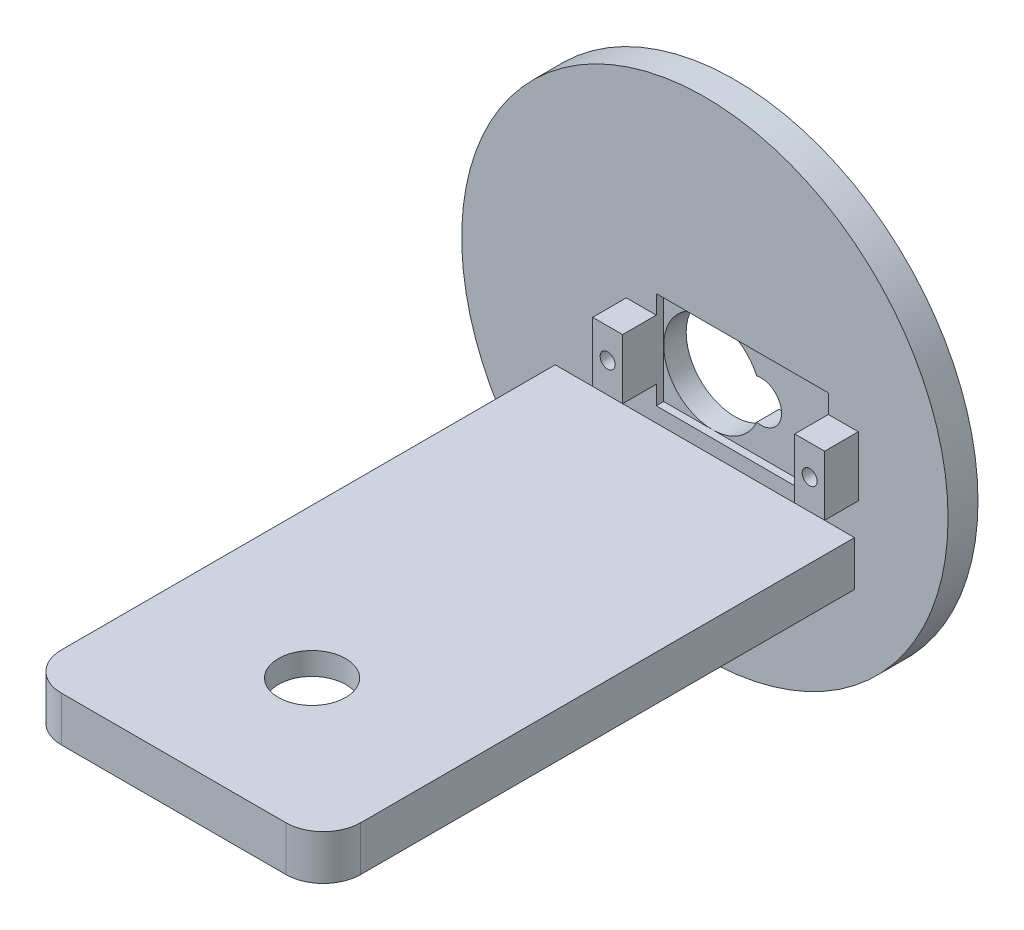
from build123d import *

# Parameters (mm, degrees)
ESBO_O1_R                = 32.5
RESSALTO_EXTRUS_O1_DEPTH = 4
ESBO_O2_W                = 4
ESBO_O2_H                = 8
ESBO_O2_R                = 1
RESSALTO_EXTRUS_O3_DEPTH = 4.5
ESBO_O3_W                = 23
ESBO_O3_H                = 13
CORTE_EXTRUS_O1_DEPTH    = 1
ESBO_O4_W                = 40
ESBO_O4_H                = 6
RESSALTO_EXTRUS_O4_DEPTH = 71
ESBO_O5_R                = 4.5
CORTE_EXTRUS_O2_DEPTH    = 61
CORTE_EXTRUS_O3_DEPTH    = 3
FILETE1_R                = 5


with BuildPart() as part:
    # Esboço1 → Ressalto-extrusão1 (new body)
    with BuildSketch(Plane.XY):
        Circle(ESBO_O1_R)
        with BuildLine():
            ThreePointArc((5.921389022, 2.680886429), (-6.5, 0), (5.921389022, -2.680886429))
            ThreePointArc((5.921389022, -2.680886429), (9.242616034, 0), (5.921389022, 2.680886429))
        make_face(mode=Mode.SUBTRACT)
    extrude(amount=RESSALTO_EXTRUS_O1_DEPTH)

    # Esboço2 → Ressalto-extrusão3 (add)
    with BuildSketch(Plane.XY.offset(4)):
        with Locations((-8.5, 0)):
            Rectangle(ESBO_O2_W, ESBO_O2_H)
        with Locations((-8.5, 0)):
            Circle(ESBO_O2_R, mode=Mode.SUBTRACT)
        with Locations((18.5, 0)):
            Rectangle(ESBO_O2_W, ESBO_O2_H)
        with Locations((18.5, 0)):
            Circle(ESBO_O2_R, mode=Mode.SUBTRACT)
    extrude(amount=RESSALTO_EXTRUS_O3_DEPTH)

    # Esboço3 → Corte-extrusão1 (cut)
    with BuildSketch(Plane.XY.offset(4)):
        with Locations((5, 0)):
            Rectangle(ESBO_O3_W, ESBO_O3_H)
    extrude(amount=-CORTE_EXTRUS_O1_DEPTH, mode=Mode.SUBTRACT)

    # Esboço4 → Ressalto-extrusão4 (add)
    with BuildSketch(Plane.XY.offset(4)):
        with Locations((0, -11.5)):
            Rectangle(ESBO_O4_W, ESBO_O4_H)
    extrude(amount=RESSALTO_EXTRUS_O4_DEPTH)

    # Esboço5 → Corte-extrusão2 (cut)
    with BuildSketch(Plane.XZ.offset(14.5)):
        with Locations((0, 56.5)):
            Circle(ESBO_O5_R)
    extrude(amount=-CORTE_EXTRUS_O2_DEPTH, mode=Mode.SUBTRACT)

    # Esboço6 → Corte-extrusão3 (cut)
    with BuildSketch(Plane.XZ.offset(14.5)):
        with BuildLine():
            Line((0, 64.5), (-10.70310615, 70.032504242))
            ThreePointArc((-10.70310615, 70.032504242), (-13.151971512, 69.651971512), (-13.532504242, 67.20310615))
            Line((-13.532504242, 67.20310615), (-8, 56.5))
            Line((-8, 56.5), (-13.532504242, 45.79689385))
            ThreePointArc((-13.532504242, 45.79689385), (-13.151971512, 43.348028488), (-10.70310615, 42.967495758))
            Line((-10.70310615, 42.967495758), (0, 48.5))
            Line((0, 48.5), (10.70310615, 42.967495758))
            ThreePointArc((10.70310615, 42.967495758), (13.151971512, 43.348028488), (13.532504242, 45.79689385))
            Line((13.532504242, 45.79689385), (8, 56.5))
            Line((8, 56.5), (13.532504242, 67.20310615))
            ThreePointArc((13.532504242, 67.20310615), (13.151971512, 69.651971512), (10.70310615, 70.032504242))
            Line((10.70310615, 70.032504242), (0, 64.5))
        make_face()
    extrude(amount=-CORTE_EXTRUS_O3_DEPTH, mode=Mode.SUBTRACT)

    # Filete1
    filete1_edges = [part.edges().sort_by_distance(p)[0] for p in [
        (20, -11.5, 75),
        (-20, -11.5, 75),
    ]]
    fillet(filete1_edges, radius=FILETE1_R)


solid = part.part
